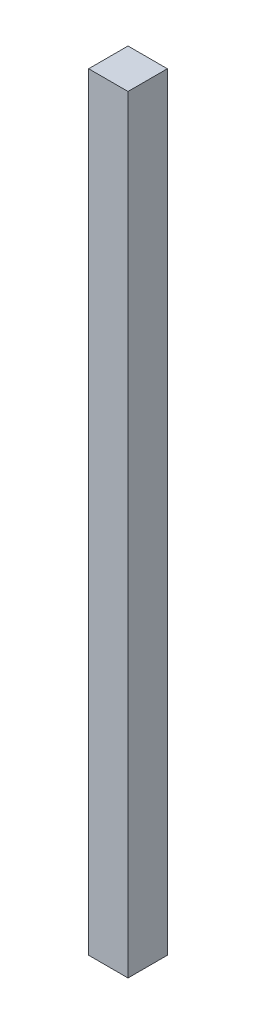
from build123d import *

# Parameters (mm, degrees)
SKETCH2_W           = 3.175
SKETCH2_H           = 61.92012
BOSS_EXTRUDE1_DEPTH = 3.175


with BuildPart() as part:
    # Sketch2 → Boss-Extrude1 (new body)
    with BuildSketch(Plane.XY):
        Rectangle(SKETCH2_W, SKETCH2_H)
    extrude(amount=BOSS_EXTRUDE1_DEPTH)


solid = part.part
